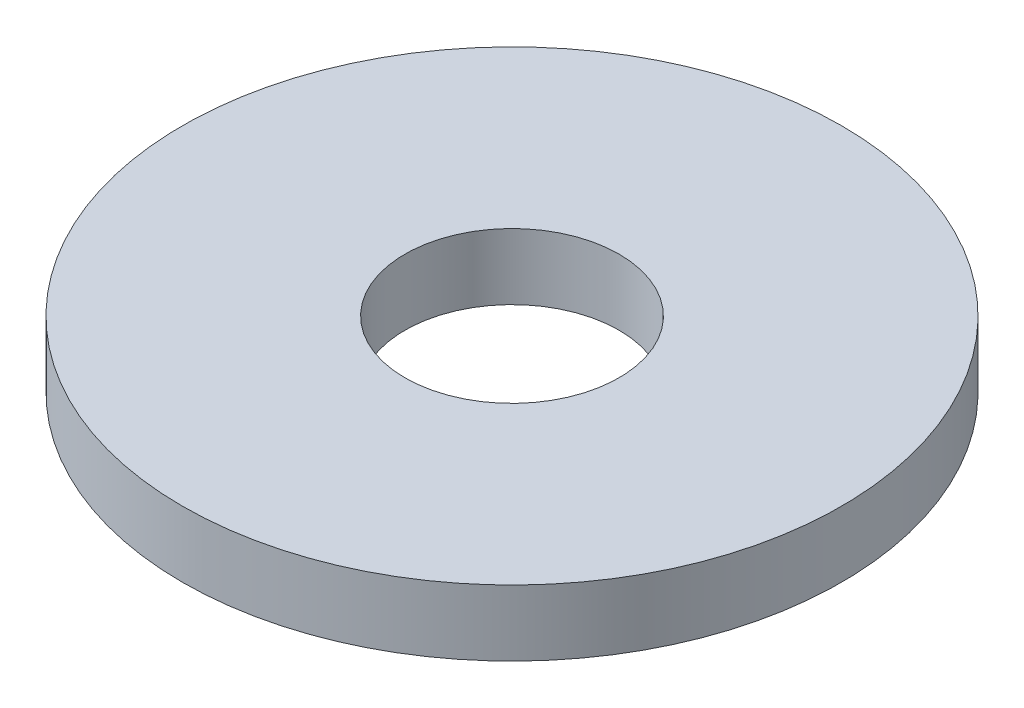
from build123d import *

# Parameters (mm, degrees)
ESQUISSE1_R        = 10
ESQUISSE1_R_2      = 3.25
BOSS_EXTRU_1_DEPTH = 2


with BuildPart() as part:
    # Esquisse1 → Boss.-Extru.1 (new body)
    with BuildSketch(Plane(origin=(0, 0, 0), x_dir=(1, 0, 0), z_dir=(0, 1, 0))):
        Circle(ESQUISSE1_R)
        Circle(ESQUISSE1_R_2, mode=Mode.SUBTRACT)
    extrude(amount=BOSS_EXTRU_1_DEPTH)


solid = part.part
